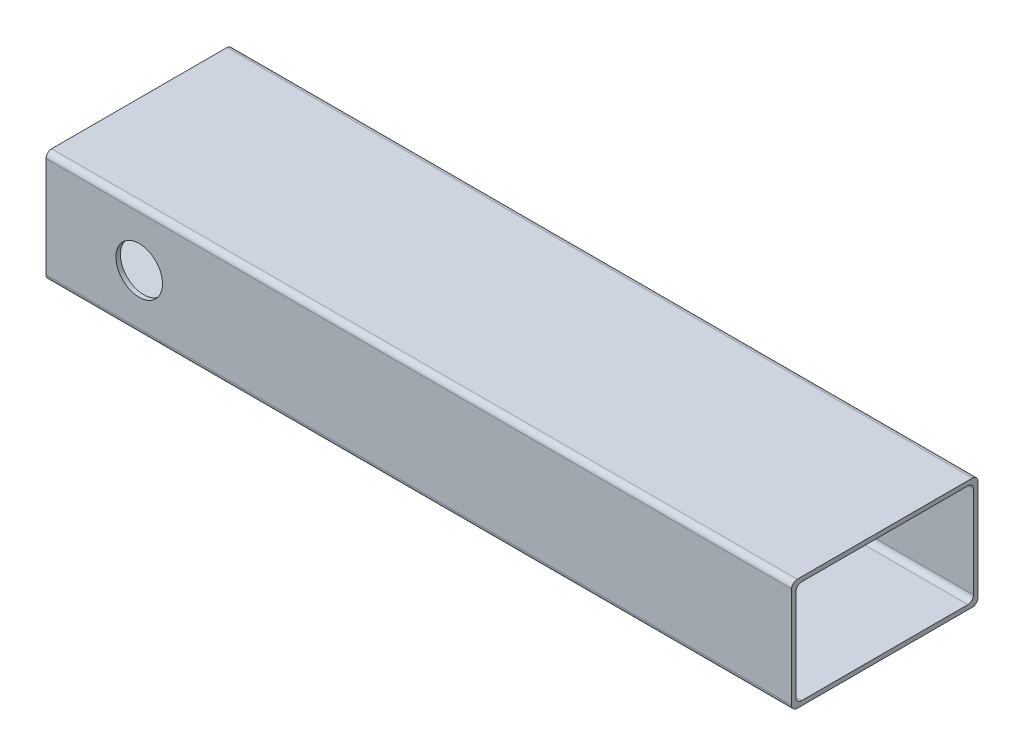
from build123d import *

# Parameters (mm, degrees)
SKETCH1_W           = 508
SKETCH1_H           = 127
BOSS_EXTRUDE1_DEPTH = 76.2
SKETCH5_W           = 120.904
SKETCH5_H           = 70.104
CUT_EXTRUDE1_DEPTH  = 509
FILLET1_R           = 3.81
SKETCH9_R           = 15.875
CUT_EXTRUDE5_DEPTH  = 128


with BuildPart() as part:
    # Sketch1 → Boss-Extrude1 (new body)
    with BuildSketch(Plane(origin=(0, 0, 0), x_dir=(1, 0, 0), z_dir=(0, 1, 0))):
        with Locations((-33.748251748, 0.444055944)):
            Rectangle(SKETCH1_W, SKETCH1_H)
    extrude(amount=BOSS_EXTRUDE1_DEPTH)

    # Sketch5 → Cut-Extrude1 (cut, through all)
    with BuildSketch(Plane.ZY.offset(287.748251748)):
        with Locations((-0.444055944, 38.1)):
            Rectangle(SKETCH5_W, SKETCH5_H)
    extrude(amount=-CUT_EXTRUDE1_DEPTH, mode=Mode.SUBTRACT)

    # Fillet1
    fillet1_edges = [part.edges().sort_by_distance(p)[0] for p in [
        (-33.748251748, 76.2, -63.944055944),
        (-33.748251748, 3.048, -60.896055944),
        (-33.748251748, 73.152, -60.896055944),
        (-33.748251748, 73.152, 60.007944056),
        (-33.748251748, 3.048, 60.007944056),
        (-33.748251748, 0, -63.944055944),
        (-33.748251748, 0, 63.055944056),
        (-33.748251748, 76.2, 63.055944056),
    ]]
    fillet(fillet1_edges, radius=FILLET1_R)

    # Sketch9 → Cut-Extrude5 (cut, through all)
    with BuildSketch(Plane.XY.offset(63.055944056)):
        with Locations((-224.248251748, 38.1)):
            Circle(SKETCH9_R)
    extrude(amount=-CUT_EXTRUDE5_DEPTH, mode=Mode.SUBTRACT)


solid = part.part
